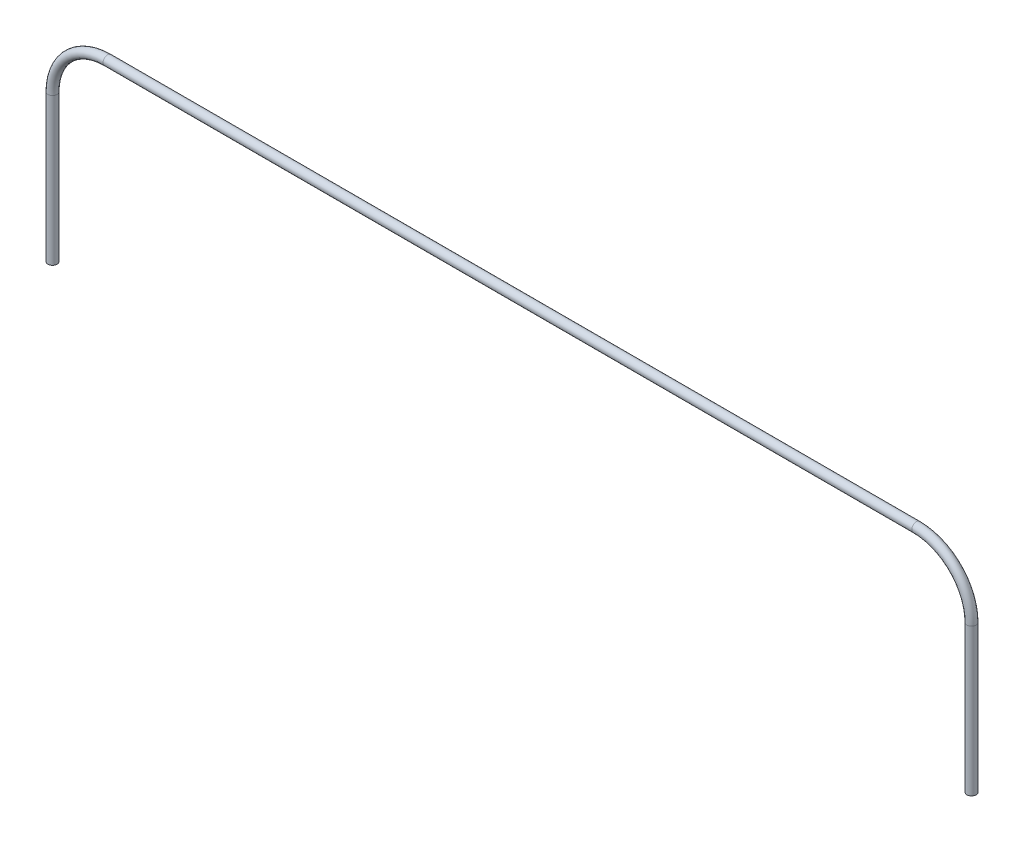
from build123d import *

# Parameters (mm, degrees)
ESQUISSE4_R = 0.25


with BuildPart() as part:
    # Balayage1: sweep along a path in Esquisse1
    with BuildLine(Plane.XY) as balayage1_path:
        Line((0, 0), (0, 8))
        ThreePointArc((0, 8), (0.878679656, 10.121320344), (3, 11))
        Line((3, 11), (47, 11))
        ThreePointArc((47, 11), (49.121320344, 10.121320344), (50, 8))
        Line((50, 8), (50, 0))
    # Esquisse4 → Balayage1 (sweep)
    with BuildSketch(Plane(origin=(0, 0, 0), x_dir=(1, 0, 0), z_dir=(0, 1, 0))):
        Circle(ESQUISSE4_R)
    sweep(path=balayage1_path.line)


solid = part.part
